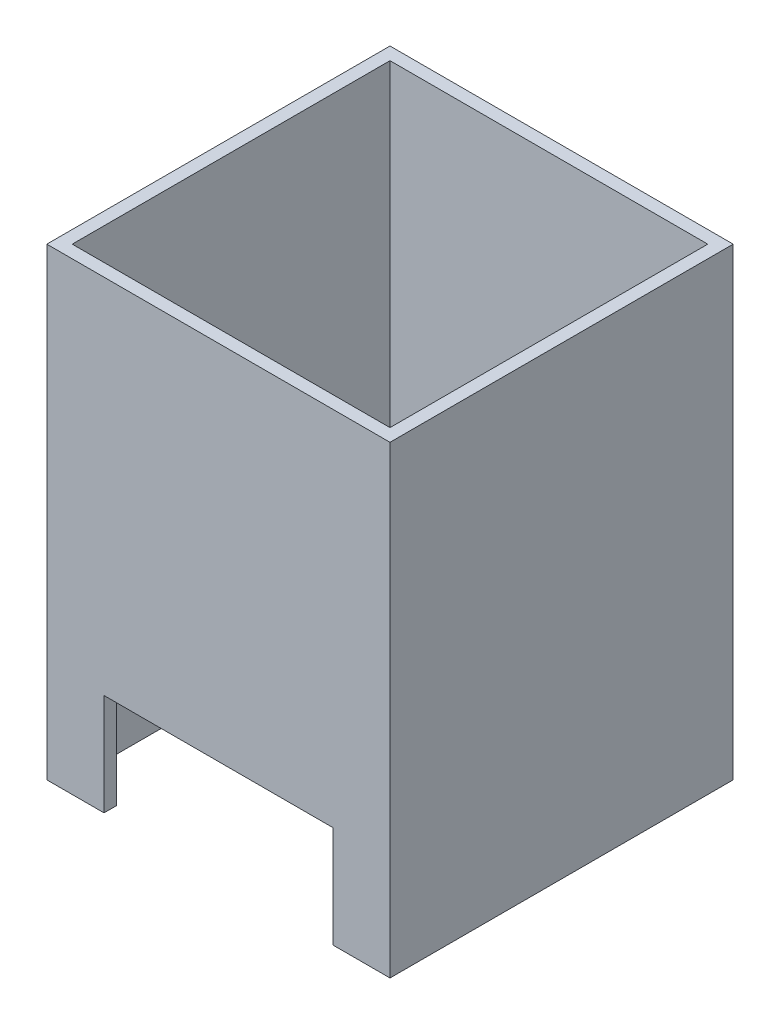
from build123d import *

# Parameters (mm, degrees)
SKETCH1_W           = 54
SKETCH1_H           = 54
SKETCH1_W_2         = 50
SKETCH1_H_2         = 50
BOSS_EXTRUDE1_DEPTH = 22
SKETCH2_W           = 54
SKETCH2_H           = 54
BOSS_EXTRUDE2_DEPTH = 1
SKETCH3_R           = 6
CUT_EXTRUDE1_DEPTH  = 24
SKETCH4_W           = 2
SKETCH4_H           = 50
SKETCH4_H_2         = 2
SKETCH4_W_2         = 50
BOSS_EXTRUDE3_DEPTH = 50
SKETCH5_W           = 33
SKETCH5_H           = 33
CUT_EXTRUDE2_DEPTH  = 52
CUT_EXTRUDE3_REACH  = 56
SKETCH6_W           = 36
SKETCH6_H           = 16


with BuildPart() as part:
    # Sketch1 → Boss-Extrude1 (new body)
    with BuildSketch(Plane(origin=(0, 0, 0), x_dir=(1, 0, 0), z_dir=(0, 1, 0))):
        Rectangle(SKETCH1_W, SKETCH1_H)
        Rectangle(SKETCH1_W_2, SKETCH1_H_2, mode=Mode.SUBTRACT)
    extrude(amount=BOSS_EXTRUDE1_DEPTH)

    # Sketch2 → Boss-Extrude2 (add)
    with BuildSketch(Plane(origin=(0, 22, 0), x_dir=(1, 0, 0), z_dir=(0, 1, 0))):
        Rectangle(SKETCH2_W, SKETCH2_H)
    extrude(amount=BOSS_EXTRUDE2_DEPTH)

    # Sketch3 → Cut-Extrude1 (cut, through all)
    with BuildSketch(Plane(origin=(0, 23, 0), x_dir=(1, 0, 0), z_dir=(0, 1, 0))):
        Circle(SKETCH3_R)
    extrude(amount=-CUT_EXTRUDE1_DEPTH, mode=Mode.SUBTRACT)

    # Sketch4 → Boss-Extrude3 (add)
    with BuildSketch(Plane(origin=(0, 23, 0), x_dir=(1, 0, 0), z_dir=(0, 1, 0))):
        with Locations((-26, 0)):
            Rectangle(SKETCH4_W, SKETCH4_H)
        with Locations((-26, -26)):
            Rectangle(SKETCH4_W, SKETCH4_H_2)
        with Locations((0, -26)):
            Rectangle(SKETCH4_W_2, SKETCH4_H_2)
        with Locations((26, -26)):
            Rectangle(SKETCH4_W, SKETCH4_H_2)
        with Locations((26, 0)):
            Rectangle(SKETCH4_W, SKETCH4_H)
        with Locations((26, 26)):
            Rectangle(SKETCH4_W, SKETCH4_H_2)
        with Locations((0, 26)):
            Rectangle(SKETCH4_W_2, SKETCH4_H_2)
        with Locations((-26, 26)):
            Rectangle(SKETCH4_W, SKETCH4_H_2)
    extrude(amount=BOSS_EXTRUDE3_DEPTH)

    # Sketch5 → Cut-Extrude2 (cut, through all)
    with BuildSketch(Plane.XZ.offset(-22)):
        Rectangle(SKETCH5_W, SKETCH5_H)
    extrude(amount=-CUT_EXTRUDE2_DEPTH, mode=Mode.SUBTRACT)

    # Sketch6 → Cut-Extrude3 (cut, up to next)
    with BuildSketch(Plane.XY.offset(27), mode=Mode.PRIVATE) as cut_extrude3_sk1:
        with Locations((0, 8)):
            Rectangle(SKETCH6_W, SKETCH6_H)
    cut_extrude3_tool1 = extrude(cut_extrude3_sk1.sketch, amount=-CUT_EXTRUDE3_REACH, mode=Mode.PRIVATE) & part.part
    add(cut_extrude3_tool1.solids().sort_by_distance((0, 8, 27))[0], mode=Mode.SUBTRACT)


solid = part.part
